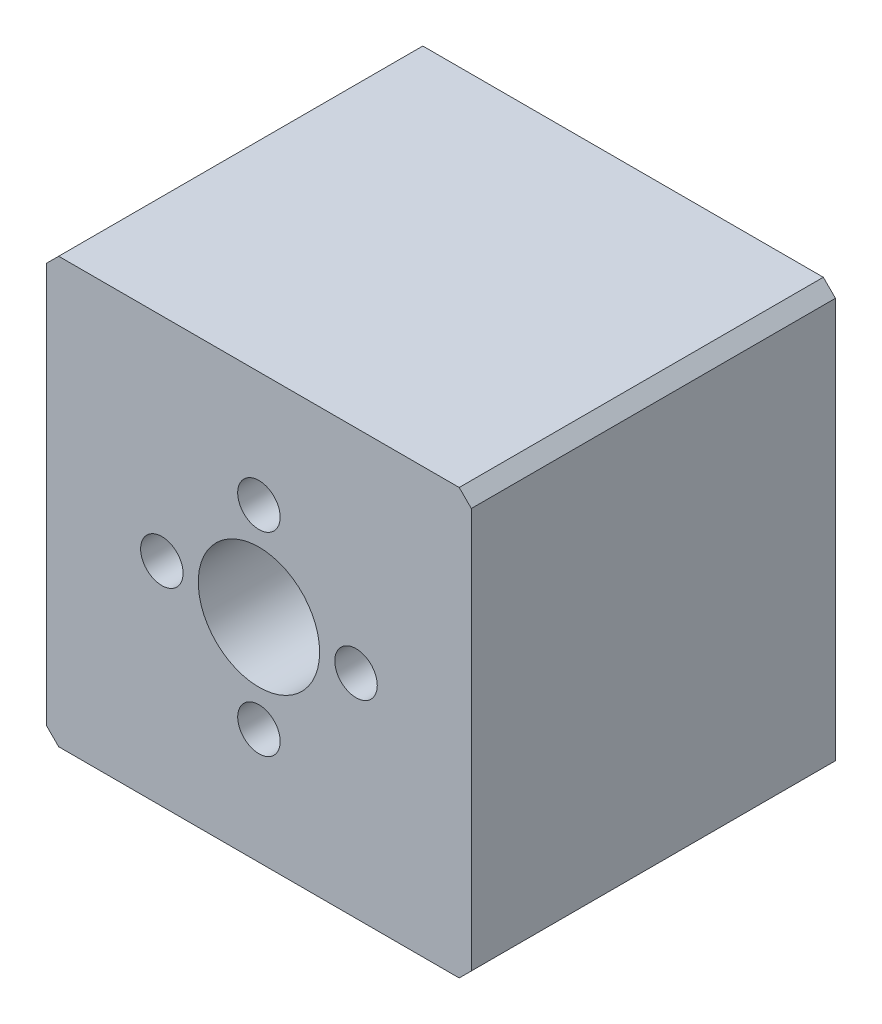
from build123d import *

# Parameters (mm, degrees)
SKETCH1_W           = 35
SKETCH1_H           = 35
SKETCH1_R           = 5
BOSS_EXTRUDE1_DEPTH = 15
SKETCH2_R           = 1.75
CUT_EXTRUDE1_DEPTH  = 10
CHAMFER1_SIZE       = 1
SKETCH3_R           = 2
CUT_EXTRUDE2_DEPTH  = 10


with BuildPart() as part:
    # Sketch1 → Boss-Extrude1 (new body, symmetric)
    with BuildSketch(Plane.XY):
        with Locations((0, 1.5)):
            Rectangle(SKETCH1_W, SKETCH1_H)
        with Locations((0, 1.5)):
            Circle(SKETCH1_R, mode=Mode.SUBTRACT)
    extrude(amount=BOSS_EXTRUDE1_DEPTH, both=True)

    # Sketch2 → Cut-Extrude1 (cut)
    with BuildSketch(Plane.XY.offset(15)):
        with Locations((0, 9.5)):
            Circle(SKETCH2_R)
        with Locations((0, -6.5)):
            Circle(SKETCH2_R)
        with Locations((8, 1.5)):
            Circle(SKETCH2_R)
        with Locations((-8, 1.5)):
            Circle(SKETCH2_R)
    extrude(amount=-CUT_EXTRUDE1_DEPTH, mode=Mode.SUBTRACT)

    # Chamfer1
    chamfer1_edges = [part.edges().sort_by_distance(p)[0] for p in [
        (-17.5, 19, 0),
        (17.5, 19, 0),
        (17.5, -16, 0),
        (-17.5, -16, 0),
    ]]
    chamfer(chamfer1_edges, length=CHAMFER1_SIZE)

    # Sketch3 → Cut-Extrude2 (cut)
    with BuildSketch(Plane.XZ.offset(16)):
        with Locations((12.5, 8)):
            Circle(SKETCH3_R)
        with Locations((12.5, -8)):
            Circle(SKETCH3_R)
    cut_extrude2 = extrude(amount=-CUT_EXTRUDE2_DEPTH, mode=Mode.SUBTRACT)

    # Mirror1: Cut-Extrude2 across plane
    add(cut_extrude2.mirror(Plane(origin=(0, 0, 0), x_dir=(0, 0, 1), z_dir=(1, 0, 0))), mode=Mode.SUBTRACT)


solid = part.part
